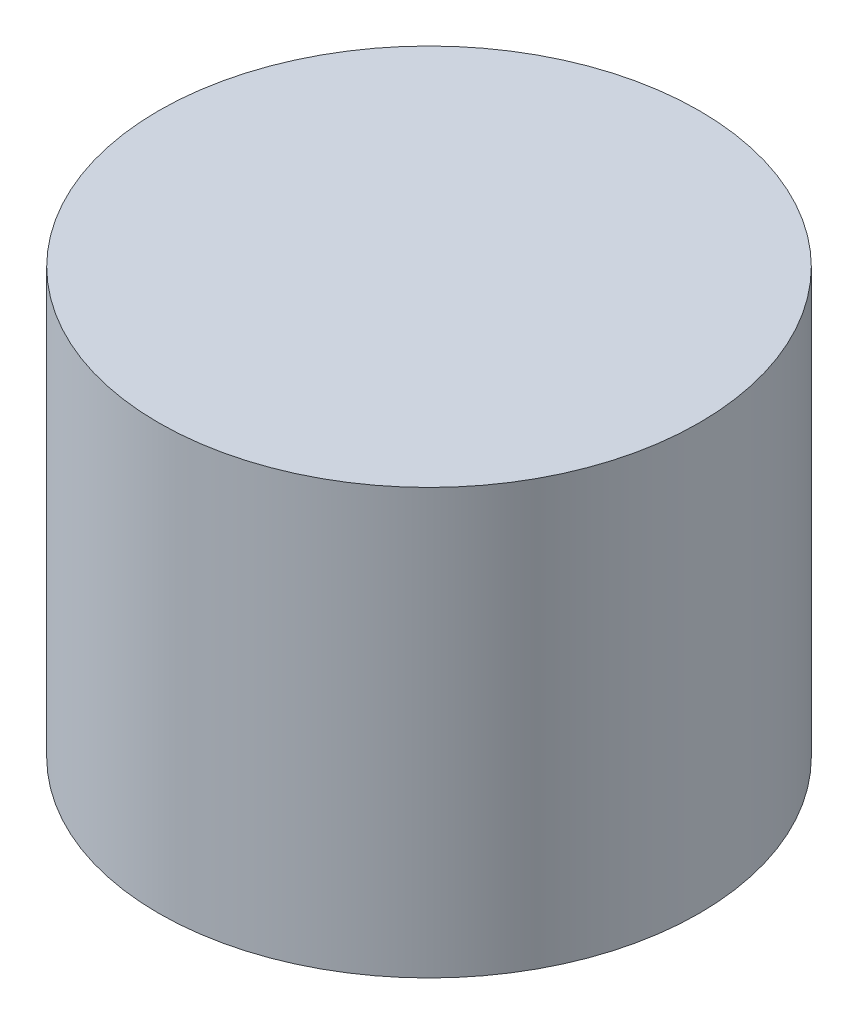
from build123d import *

# Parameters (mm, degrees)
SKETCH1_R           = 14
BOSS_EXTRUDE1_DEPTH = 22


with BuildPart() as part:
    # Sketch1 → Boss-Extrude1 (new body)
    with BuildSketch(Plane(origin=(0, 0, 0), x_dir=(1, 0, 0), z_dir=(0, 1, 0))):
        Circle(SKETCH1_R)
    extrude(amount=BOSS_EXTRUDE1_DEPTH)


solid = part.part
